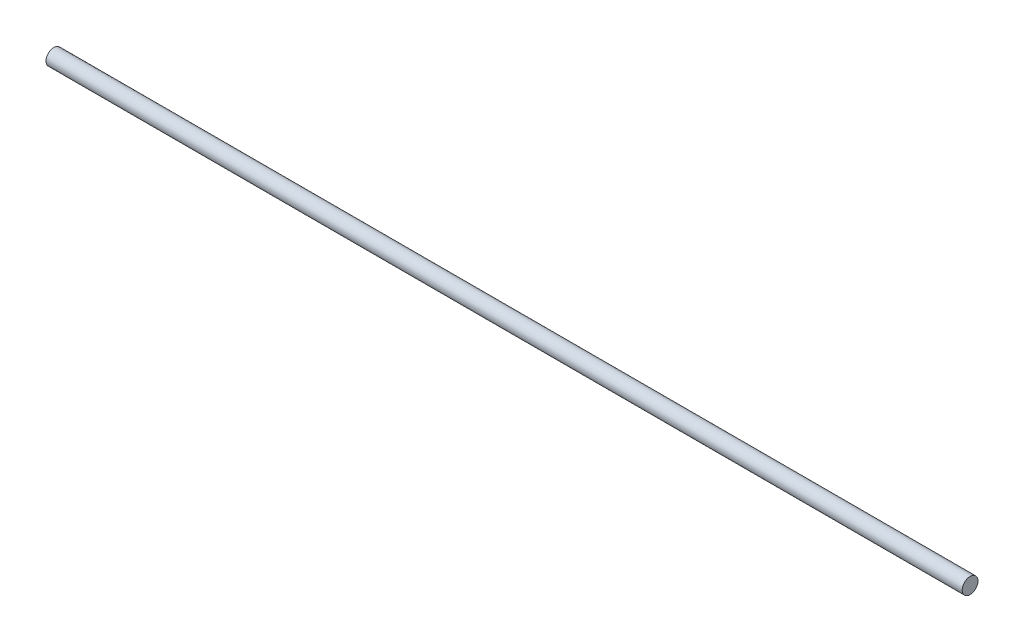
from build123d import *

# Parameters (mm, degrees)
SKETCH1_R           = 5
BOSS_EXTRUDE1_DEPTH = 580


with BuildPart() as part:
    # Sketch1 → Boss-Extrude1 (new body)
    with BuildSketch(Plane(origin=(0, 0, 0), x_dir=(0, 0, -1), z_dir=(1, 0, 0))):
        Circle(SKETCH1_R)
    extrude(amount=BOSS_EXTRUDE1_DEPTH)


solid = part.part
